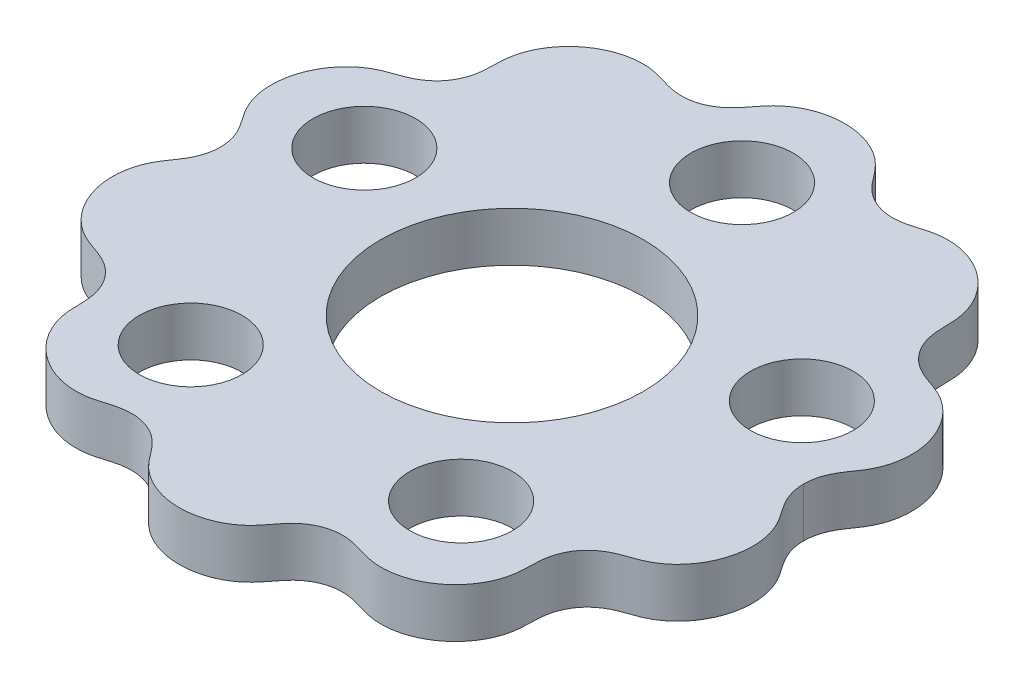
from build123d import *

# Parameters (mm, degrees)
BOSS_EXTRUDE1_DEPTH = 6
SKETCH3_R           = 16
SKETCH3_R_2         = 6.25
CUT_EXTRUDE1_DEPTH  = 6


with BuildPart() as part:
    # Sketch2 → Boss-Extrude1 (new body)
    with BuildSketch(Plane(origin=(0, 0, 0), x_dir=(1, 0, 0), z_dir=(0, 1, 0))):
        with BuildLine():
            add(Edge.make_bspline(
                [(35.500002866, 0), (35.500002908, -0.004332362), (35.500160704, -0.164655465), (35.511879707, -0.480956083), (35.562951828, -0.951397357), (35.694699212, -1.562368334), (35.914803433, -2.241772004), (36.248669896, -2.972863416), (36.711646609, -3.73642892), (37.288335581, -4.528120264), (37.873230618, -5.397526859), (38.376435584, -6.395139964), (38.829147471, -7.752618741), (39.061186651, -9.486887672), (38.924485825, -11.206163975), (38.461464959, -12.829866386), (37.865262684, -14.105916421), (37.263886174, -15.067184484), (36.528816331, -15.968364434), (35.658095269, -16.78364031), (34.709454256, -17.441704457), (33.710748389, -17.938096133), (32.726010532, -18.286487189), (31.798904046, -18.591313455), (30.838907854, -19.008063231), (29.891435788, -19.599392059), (29.016567056, -20.406856316), (28.289724628, -21.437349615), (27.82335305, -22.530873581), (27.582593406, -23.617744703), (27.503747384, -24.651249016), (27.505009019, -25.611426609), (27.465134177, -26.645971238), (27.310719606, -27.587694342), (27.069241338, -28.42319667), (26.625528619, -29.524280019), (25.91052288, -30.771524249), (24.704452738, -32.174130803), (22.873307303, -33.4892481), (21.010167902, -34.243714394), (19.275416565, -34.542934447), (17.83486411, -34.513723012), (16.724226883, -34.32632605), (15.714061835, -34.025592827), (14.777346051, -33.725368286), (13.745665007, -33.499389036), (12.619878747, -33.426163211), (11.437780741, -33.574707648), (10.256902106, -33.987167073), (9.250869505, -34.595539883), (8.42935215, -35.32376419), (7.76144971, -36.109169474), (7.195963595, -36.890135964), (6.558615711, -37.69894771), (5.779602594, -38.470120814), (4.650245939, -39.307487967), (3.102574359, -40.059315642), (1.176214207, -40.536281656), (-1.067650804, -40.551186023), (-3.015485272, -40.093173964), (-4.59784453, -39.340344925), (-5.747267121, -38.498115381), (-6.535201174, -37.725799019), (-7.17822933, -36.914382673), (-7.74644274, -36.129342529), (-8.613444237, -35.102163686), (-9.734463077, -34.209866547), (-11.128614422, -33.613701708), (-12.619442372, -33.4261591), (-13.745975356, -33.499367909), (-14.777075894, -33.725427517), (-15.714326937, -34.025465326), (-16.572772996, -34.281493993), (-17.367092698, -34.434620135), (-18.239875034, -34.522051234), (-19.431977282, -34.515847736), (-21.010097343, -34.243797127), (-22.873341958, -33.48919367), (-24.704449556, -32.174164964), (-25.910491719, -30.771510601), (-26.62558752, -29.524277129), (-27.010440703, -28.568908412), (-27.200396118, -27.969916552), (-27.361500625, -27.276936084), (-27.471364462, -26.488953233), (-27.504885527, -25.611451081), (-27.50381276, -24.651236043), (-27.582559056, -23.617751522), (-27.823373692, -22.530869483), (-28.289711823, -21.437352157), (-29.01657507, -20.406854725), (-29.891430839, -19.599393042), (-30.83891096, -19.008062615), (-31.798901862, -18.591313888), (-32.726011837, -18.28648693), (-33.710747646, -17.93809628), (-34.709454701, -17.441704369), (-35.65809499, -16.783640365), (-36.528816515, -15.968364398), (-37.263886065, -15.067184505), (-37.86526274, -14.10591641), (-38.461464923, -12.829866393), (-38.924485851, -11.20616397), (-39.061186635, -9.486887675), (-38.829147479, -7.75261874), (-38.376435579, -6.395139965), (-37.873230622, -5.397526858), (-37.288335579, -4.528120265), (-36.711646611, -3.73642892), (-36.248669896, -2.972863417), (-35.914803434, -2.241772004), (-35.694699212, -1.562368334), (-35.562951828, -0.951397357), (-35.511879707, -0.480956083), (-35.500160704, -0.164655465), (-35.500002908, -0.004332362), (-35.500002866, 0)],
                knots=[0.119821733, 0.119821733, 0.119821733, 0.119821733, 0.119821733, 0.119920368, 0.123471824, 0.127023279, 0.130574734, 0.13412619, 0.139702675, 0.145279161, 0.150855646, 0.156432132, 0.163531207, 0.170630282, 0.183307857, 0.195985433, 0.202422493, 0.208859552, 0.215296612, 0.221733671, 0.228829801, 0.23592593, 0.241481333, 0.247036735, 0.252592137, 0.258147539, 0.265247155, 0.272346771, 0.279496522, 0.286646273, 0.292112754, 0.297579235, 0.303045717, 0.308512198, 0.315657632, 0.319230349, 0.322803066, 0.335512239, 0.348221412, 0.360938434, 0.373655456, 0.380833149, 0.388010841, 0.393610253, 0.399209665, 0.404809078, 0.41040849, 0.417590751, 0.424773011, 0.431726804, 0.438680597, 0.444170222, 0.449659847, 0.455149472, 0.460639097, 0.467586663, 0.47453423, 0.487038428, 0.499542626, 0.512346511, 0.525150396, 0.532151462, 0.539152527, 0.544667676, 0.550182825, 0.555697974, 0.561213123, 0.575226989, 0.582409249, 0.58959151, 0.595190922, 0.600790335, 0.606389747, 0.611989159, 0.615578005, 0.619166851, 0.626344544, 0.639061566, 0.651778588, 0.664487761, 0.677196934, 0.680769651, 0.684342368, 0.687915085, 0.691487802, 0.696954283, 0.702420765, 0.707887246, 0.713353727, 0.720503478, 0.727653229, 0.734752845, 0.741852461, 0.747407863, 0.752963265, 0.758518667, 0.76407407, 0.771170199, 0.778266329, 0.784703388, 0.791140448, 0.797577507, 0.804014567, 0.816692143, 0.829369718, 0.836468793, 0.843567868, 0.849144354, 0.854720839, 0.860297325, 0.86587381, 0.869425266, 0.872976721, 0.876528176, 0.880079632, 0.880178267, 0.880178267, 0.880178267, 0.880178267, 0.880178267], degree=4))
            add(Edge.make_bspline(
                [(35.500002866, 0), (35.500002908, 0.004332362), (35.500160704, 0.164655465), (35.511879707, 0.480956083), (35.562951828, 0.951397357), (35.694699212, 1.562368334), (35.914803433, 2.241772004), (36.248669896, 2.972863416), (36.711646609, 3.73642892), (37.288335581, 4.528120264), (37.873230618, 5.397526859), (38.376435584, 6.395139964), (38.829147471, 7.752618741), (39.061186651, 9.486887672), (38.924485825, 11.206163975), (38.461464959, 12.829866386), (37.865262684, 14.105916421), (37.263886174, 15.067184484), (36.528816331, 15.968364434), (35.658095269, 16.78364031), (34.709454256, 17.441704457), (33.710748389, 17.938096133), (32.726010532, 18.286487189), (31.798904046, 18.591313455), (30.838907854, 19.008063231), (29.891435788, 19.599392059), (29.016567056, 20.406856316), (28.289724628, 21.437349615), (27.82335305, 22.530873581), (27.582593406, 23.617744703), (27.503747384, 24.651249016), (27.505009019, 25.611426609), (27.465134177, 26.645971238), (27.310719606, 27.587694342), (27.069241338, 28.42319667), (26.625528619, 29.524280019), (25.91052288, 30.771524249), (24.704452738, 32.174130803), (22.873307303, 33.4892481), (21.010167902, 34.243714394), (19.275416565, 34.542934447), (17.83486411, 34.513723012), (16.724226883, 34.32632605), (15.714061835, 34.025592827), (14.777346051, 33.725368286), (13.745665007, 33.499389036), (12.619878747, 33.426163211), (11.437780741, 33.574707648), (10.256902106, 33.987167073), (9.250869505, 34.595539883), (8.42935215, 35.32376419), (7.76144971, 36.109169474), (7.195963595, 36.890135964), (6.558615711, 37.69894771), (5.779602594, 38.470120814), (4.650245939, 39.307487967), (3.102574359, 40.059315642), (1.176214207, 40.536281656), (-1.067650804, 40.551186023), (-3.015485272, 40.093173964), (-4.59784453, 39.340344925), (-5.747267121, 38.498115381), (-6.535201174, 37.725799019), (-7.17822933, 36.914382673), (-7.74644274, 36.129342529), (-8.613444237, 35.102163686), (-9.734463077, 34.209866547), (-11.128614422, 33.613701708), (-12.619442372, 33.4261591), (-13.745975356, 33.499367909), (-14.777075894, 33.725427517), (-15.714326937, 34.025465326), (-16.572772996, 34.281493993), (-17.367092698, 34.434620135), (-18.239875034, 34.522051234), (-19.431977282, 34.515847736), (-21.010097343, 34.243797127), (-22.873341958, 33.48919367), (-24.704449556, 32.174164964), (-25.910491719, 30.771510601), (-26.62558752, 29.524277129), (-27.010440703, 28.568908412), (-27.200396118, 27.969916552), (-27.361500625, 27.276936084), (-27.471364462, 26.488953233), (-27.504885527, 25.611451081), (-27.50381276, 24.651236043), (-27.582559056, 23.617751522), (-27.823373692, 22.530869483), (-28.289711823, 21.437352157), (-29.01657507, 20.406854725), (-29.891430839, 19.599393042), (-30.83891096, 19.008062615), (-31.798901862, 18.591313888), (-32.726011837, 18.28648693), (-33.710747646, 17.93809628), (-34.709454701, 17.441704369), (-35.65809499, 16.783640365), (-36.528816515, 15.968364398), (-37.263886065, 15.067184505), (-37.86526274, 14.10591641), (-38.461464923, 12.829866393), (-38.924485851, 11.20616397), (-39.061186635, 9.486887675), (-38.829147479, 7.75261874), (-38.376435579, 6.395139965), (-37.873230622, 5.397526858), (-37.288335579, 4.528120265), (-36.711646611, 3.73642892), (-36.248669896, 2.972863417), (-35.914803434, 2.241772004), (-35.694699212, 1.562368334), (-35.562951828, 0.951397357), (-35.511879707, 0.480956083), (-35.500160704, 0.164655465), (-35.500002908, 0.004332362), (-35.500002866, 0)],
                knots=[0.119821733, 0.119821733, 0.119821733, 0.119821733, 0.119821733, 0.119920368, 0.123471824, 0.127023279, 0.130574734, 0.13412619, 0.139702675, 0.145279161, 0.150855646, 0.156432132, 0.163531207, 0.170630282, 0.183307857, 0.195985433, 0.202422493, 0.208859552, 0.215296612, 0.221733671, 0.228829801, 0.23592593, 0.241481333, 0.247036735, 0.252592137, 0.258147539, 0.265247155, 0.272346771, 0.279496522, 0.286646273, 0.292112754, 0.297579235, 0.303045717, 0.308512198, 0.315657632, 0.319230349, 0.322803066, 0.335512239, 0.348221412, 0.360938434, 0.373655456, 0.380833149, 0.388010841, 0.393610253, 0.399209665, 0.404809078, 0.41040849, 0.417590751, 0.424773011, 0.431726804, 0.438680597, 0.444170222, 0.449659847, 0.455149472, 0.460639097, 0.467586663, 0.47453423, 0.487038428, 0.499542626, 0.512346511, 0.525150396, 0.532151462, 0.539152527, 0.544667676, 0.550182825, 0.555697974, 0.561213123, 0.575226989, 0.582409249, 0.58959151, 0.595190922, 0.600790335, 0.606389747, 0.611989159, 0.615578005, 0.619166851, 0.626344544, 0.639061566, 0.651778588, 0.664487761, 0.677196934, 0.680769651, 0.684342368, 0.687915085, 0.691487802, 0.696954283, 0.702420765, 0.707887246, 0.713353727, 0.720503478, 0.727653229, 0.734752845, 0.741852461, 0.747407863, 0.752963265, 0.758518667, 0.76407407, 0.771170199, 0.778266329, 0.784703388, 0.791140448, 0.797577507, 0.804014567, 0.816692143, 0.829369718, 0.836468793, 0.843567868, 0.849144354, 0.854720839, 0.860297325, 0.86587381, 0.869425266, 0.872976721, 0.876528176, 0.880079632, 0.880178267, 0.880178267, 0.880178267, 0.880178267, 0.880178267], degree=4))
        make_face()
    extrude(amount=BOSS_EXTRUDE1_DEPTH)

    # Sketch3 → Cut-Extrude1 (cut)
    with BuildSketch(Plane(origin=(0, 6, 0), x_dir=(1, 0, 0), z_dir=(0, 1, 0))):
        with Locations(Location((0, 0, 0), (0, 0, 270))):
            Circle(SKETCH3_R)
        with Locations(Location((26.629568285, 8.652519456, 0), (0, 0, 270))):
            Circle(SKETCH3_R_2)
        with Locations(Location((16.458024164, -22.652448888, 0), (0, 0, 270))):
            Circle(SKETCH3_R_2)
        with Locations(Location((-16.457949965, -22.652502797, 0), (0, 0, 270))):
            Circle(SKETCH3_R_2)
        with Locations(Location((-26.629596627, 8.652432229, 0), (0, 0, 270))):
            Circle(SKETCH3_R_2)
        with Locations(Location((-4.5858e-05, 28, 0), (0, 0, 270))):
            Circle(SKETCH3_R_2)
    extrude(amount=-CUT_EXTRUDE1_DEPTH, mode=Mode.SUBTRACT)


solid = part.part
